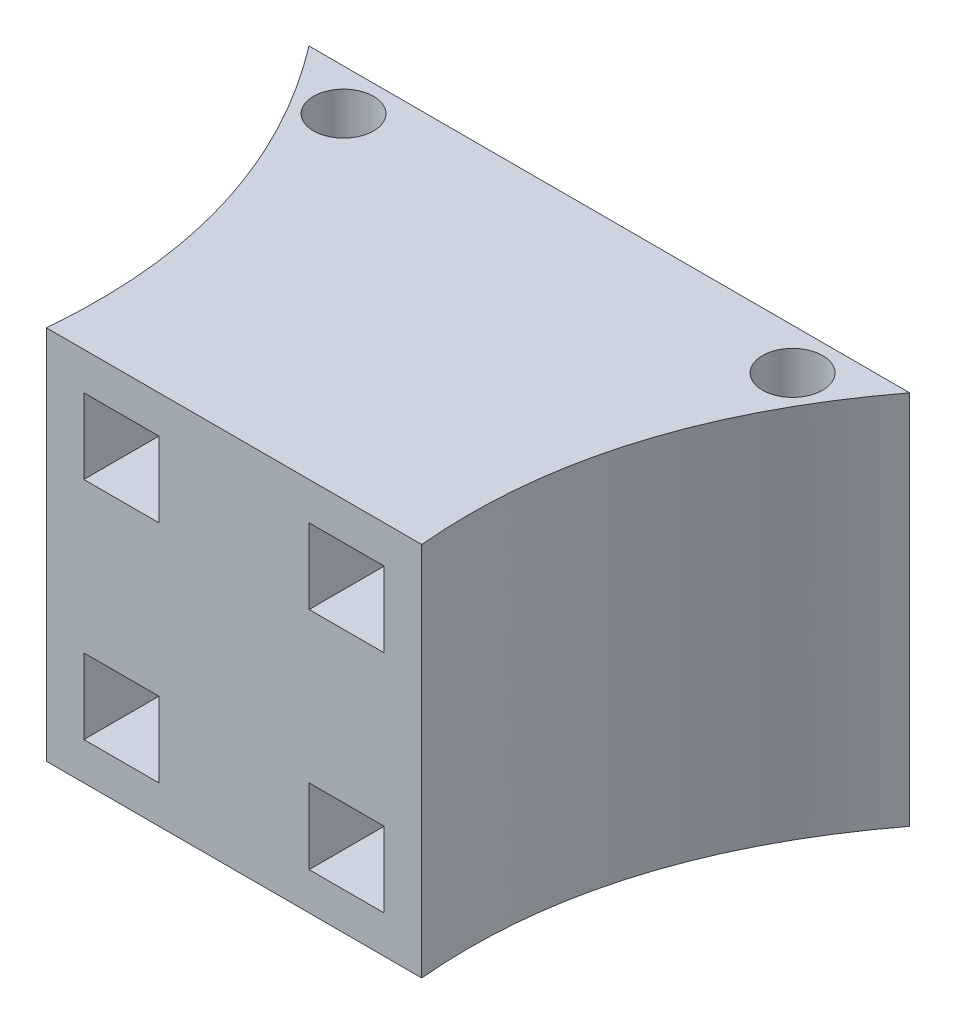
from build123d import *

# Parameters (mm, degrees)
BOSS_EXTRUDE1_DEPTH = 127
SKETCH3_W           = 25.4
SKETCH3_H           = 25.4
CUT_EXTRUDE1_DEPTH  = 63.5
SKETCH4_R           = 10.16
CUT_EXTRUDE2_DEPTH  = 128.0000001


with BuildPart() as part:
    # Sketch2 → Boss-Extrude1 (new body)
    with BuildSketch(Plane(origin=(0, 0, 0), x_dir=(1, 0, 0), z_dir=(0, 1, 0))):
        with BuildLine():
            Line((0, 0), (127, 0))
            add(Edge.make_bspline(
                [(127, 0), (120.640280387, 68.469919386), (165.1, 126.964946797)],
                knots=[0, 0, 0, 1, 1, 1], degree=2))
            Line((165.1, 126.964946797), (-38.1, 126.964946797))
            add(Edge.make_bspline(
                [(0, 0), (6.359730642, 68.469923757), (-38.1, 126.964946797)],
                knots=[0, 0, 0, 1, 1, 1], degree=2))
        make_face()
    extrude(amount=-BOSS_EXTRUDE1_DEPTH)

    # Sketch3 → Cut-Extrude1 (cut)
    with BuildSketch(Plane.XY):
        with Locations((25.4, -25.4)):
            Rectangle(SKETCH3_W, SKETCH3_H)
        with Locations((25.4, -101.6)):
            Rectangle(SKETCH3_W, SKETCH3_H)
        with Locations((101.6, -25.4)):
            Rectangle(SKETCH3_W, SKETCH3_H)
        with Locations((101.6, -101.6)):
            Rectangle(SKETCH3_W, SKETCH3_H)
    extrude(amount=-CUT_EXTRUDE1_DEPTH, mode=Mode.SUBTRACT)

    # Sketch4 → Cut-Extrude2 (cut, through all)
    with BuildSketch(Plane(origin=(0, 0, 0), x_dir=(1, 0, 0), z_dir=(0, 1, 0))):
        with Locations((-12.447257457, 112.994946797)):
            Circle(SKETCH4_R)
        with Locations((139.447257457, 112.994946797)):
            Circle(SKETCH4_R)
    extrude(amount=-CUT_EXTRUDE2_DEPTH, mode=Mode.SUBTRACT)


solid = part.part
